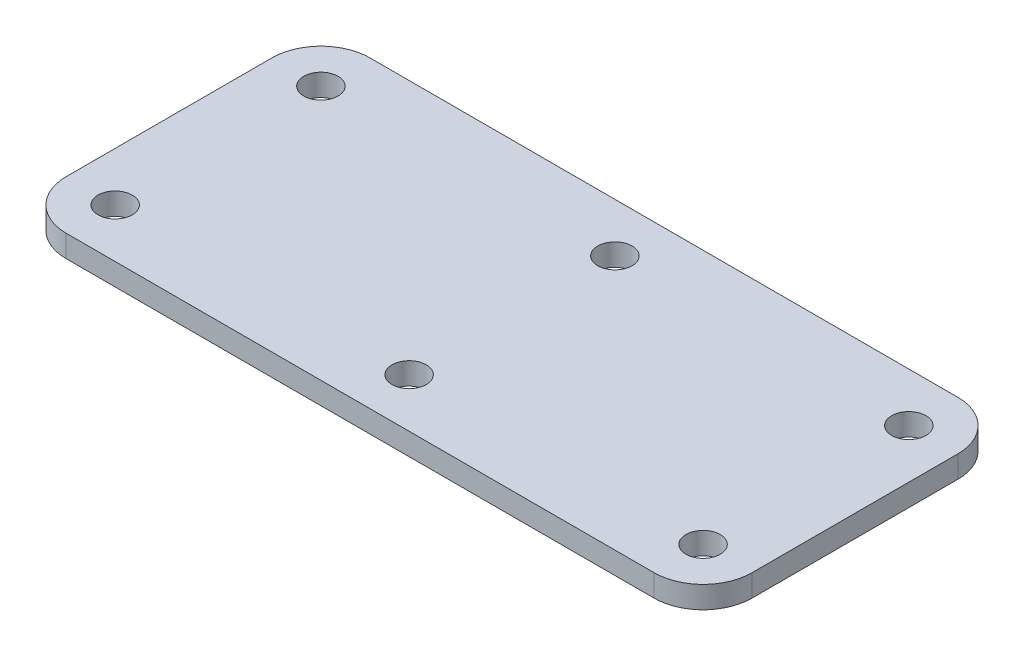
from build123d import *

# Parameters (mm, degrees)
SKETCH1_R           = 3.5
BOSS_EXTRUDE1_DEPTH = 4.5


with BuildPart() as part:
    # Sketch1 → Boss-Extrude1 (new body)
    with BuildSketch(Plane(origin=(0, 0, 0), x_dir=(1, 0, 0), z_dir=(0, 1, 0))):
        with BuildLine():
            Line((-23.732963332, -543.150162881), (96.267036668, -543.150162881))
            ThreePointArc((96.267036668, -543.150162881), (103.33810448, -546.079095069), (106.267036668, -553.150162881))
            Line((106.267036668, -553.150162881), (106.267036668, -595.150162881))
            ThreePointArc((106.267036668, -595.150162881), (103.33810448, -602.221230693), (96.267036668, -605.150162881))
            Line((96.267036668, -605.150162881), (-23.732963332, -605.150162881))
            ThreePointArc((-23.732963332, -605.150162881), (-30.804031144, -602.221230693), (-33.732963332, -595.150162881))
            Line((-33.732963332, -595.150162881), (-33.732963332, -553.150162881))
            ThreePointArc((-33.732963332, -553.150162881), (-30.804031144, -546.079095069), (-23.732963332, -543.150162881))
        make_face()
        with Locations((36.267036668, -553.150162881)):
            Circle(SKETCH1_R, mode=Mode.SUBTRACT)
        with Locations((96.267036668, -553.150162881)):
            Circle(SKETCH1_R, mode=Mode.SUBTRACT)
        with Locations((-23.732963332, -553.150162881)):
            Circle(SKETCH1_R, mode=Mode.SUBTRACT)
        with Locations((-23.732963332, -595.150162881)):
            Circle(SKETCH1_R, mode=Mode.SUBTRACT)
        with Locations((96.267036668, -595.150162881)):
            Circle(SKETCH1_R, mode=Mode.SUBTRACT)
        with Locations((36.267036668, -595.150162881)):
            Circle(SKETCH1_R, mode=Mode.SUBTRACT)
    extrude(amount=BOSS_EXTRUDE1_DEPTH)


solid = part.part
